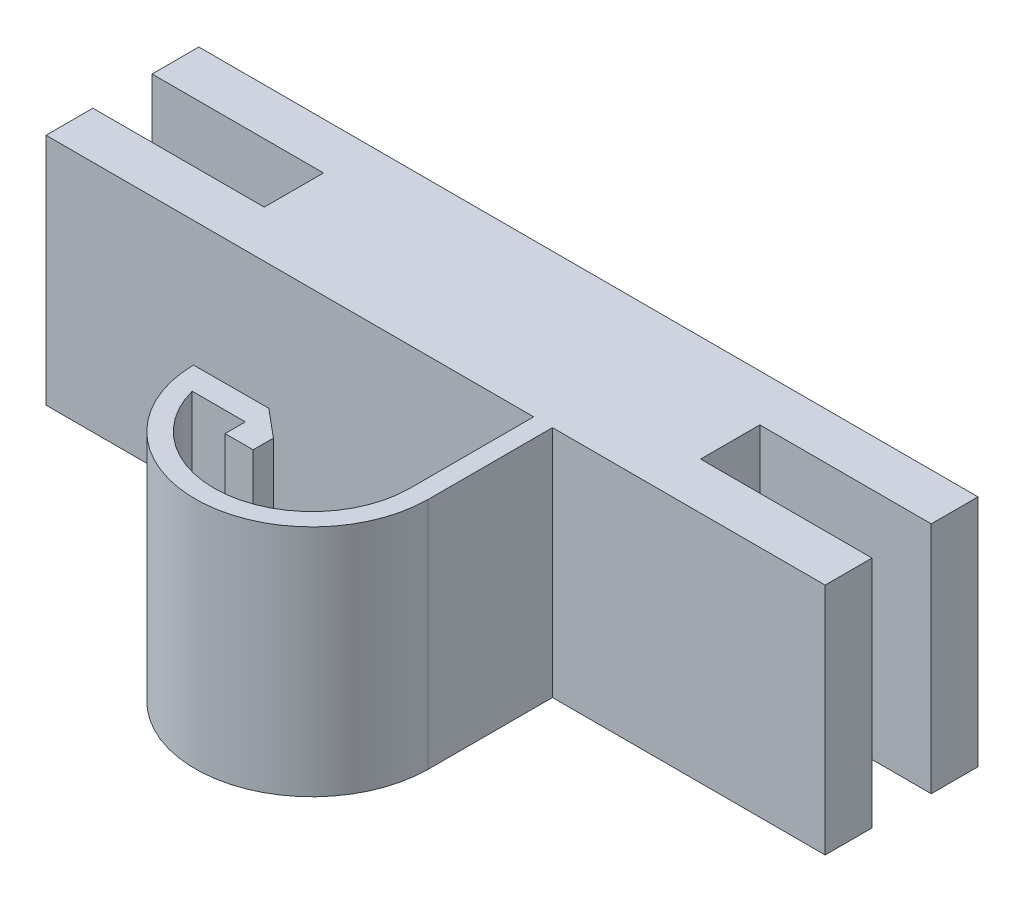
from build123d import *

# Parameters (mm, degrees)
BOSS_EXTRUDE2_DEPTH = 15


with BuildPart() as part:
    # Sketch2 → Boss-Extrude2 (new body)
    with BuildSketch(Plane(origin=(0, 0, 0), x_dir=(1, 0, 0), z_dir=(0, 1, 0))):
        with BuildLine():
            Line((-28.349494605, 21.964136687), (-17.349494605, 21.964136687))
            Line((-17.349494605, 21.964136687), (-17.349494605, 25.764136687))
            Line((-17.349494605, 25.764136687), (-28.349494605, 25.764136687))
            Line((-28.349494605, 25.764136687), (-28.349494605, 28.764136687))
            Line((-28.349494605, 28.764136687), (21.650505395, 28.764136687))
            Line((21.650505395, 28.764136687), (21.650505395, 25.764136687))
            Line((21.650505395, 25.764136687), (10.650505395, 25.764136687))
            Line((10.650505395, 25.764136687), (10.650505395, 21.964136687))
            Line((10.650505395, 21.964136687), (21.650505395, 21.964136687))
            Line((21.650505395, 21.964136687), (21.650505395, 18.957031621))
            Line((21.650505395, 18.957031621), (4.150505395, 18.957031621))
            Line((4.150505395, 18.957031621), (4.150505395, 10.957031621))
            ThreePointArc((4.150505395, 10.957031621), (-3.329004451, 3.529483044), (-10.847714263, 10.91734797))
            Line((-10.847714263, 10.91734797), (-6.026180838, 10.932389281))
            Line((-6.026180838, 10.932389281), (-4.222493535, 9.423226245))
            Line((-4.222493535, 9.423226245), (-4.222493535, 8.122210377))
            Line((-4.222493535, 8.122210377), (-6.025980027, 8.122210377))
            Line((-6.025980027, 8.122210377), (-6.025980027, 9.423279207))
            Line((-6.025980027, 9.423279207), (-9.437714366, 9.423279207))
            ThreePointArc((-9.437714366, 9.423279207), (-2.574965526, 4.779817175), (2.947813029, 10.957031621))
            Line((2.947813029, 10.957031621), (2.947813029, 18.957031621))
            Line((2.947813029, 18.957031621), (-28.349494605, 18.957031621))
            Line((-28.349494605, 18.957031621), (-28.349494605, 21.964136687))
        make_face()
    extrude(amount=BOSS_EXTRUDE2_DEPTH)


solid = part.part
